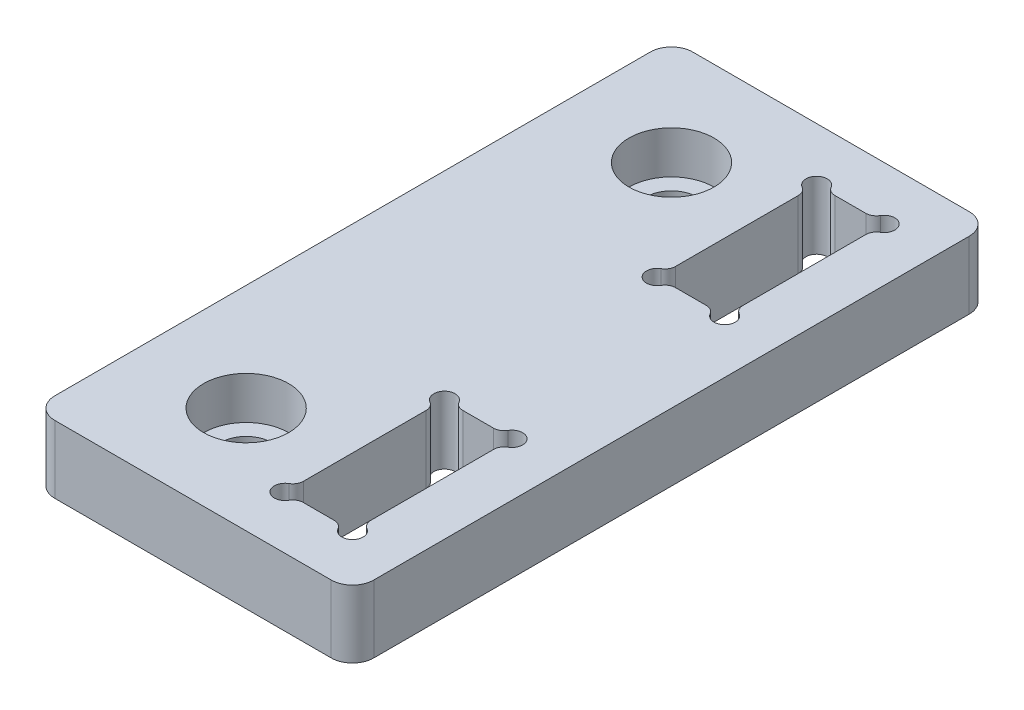
from build123d import *

# Parameters (mm, degrees)
SKETCH1_W                      = 30
SKETCH1_H                      = 60
BOSS_EXTRUDE1_DEPTH            = 6.35
CBORE_FOR_M4_SHCS1_D           = 4.8
CBORE_FOR_M4_SHCS1_DEPTH       = 6.35
CBORE_FOR_M4_SHCS1_CBORE_D     = 8
CBORE_FOR_M4_SHCS1_CBORE_DEPTH = 4
SKETCH4_W                      = 6.35
SKETCH4_H                      = 15
CUT_EXTRUDE1_DEPTH             = 7.35
SKETCH5_R                      = 1
CUT_EXTRUDE2_DEPTH             = 7.35
FILLET1_R                      = 1
FILLET2_R                      = 2


with BuildPart() as part:
    # Sketch1 → Boss-Extrude1 (new body)
    with BuildSketch(Plane(origin=(0, 0, 0), x_dir=(1, 0, 0), z_dir=(0, 1, 0))):
        Rectangle(SKETCH1_W, SKETCH1_H)
    extrude(amount=BOSS_EXTRUDE1_DEPTH)

    # CBORE for M4 SHCS1
    with Locations(Plane(origin=(0, 6.35, 0), x_dir=(1, 0, 0), z_dir=(0, 1, 0))):
        with Locations((-5, 20), (-5, -20)):
            CounterBoreHole(CBORE_FOR_M4_SHCS1_D / 2, CBORE_FOR_M4_SHCS1_CBORE_D / 2, CBORE_FOR_M4_SHCS1_CBORE_DEPTH, depth=CBORE_FOR_M4_SHCS1_DEPTH)

    # Sketch4 → Cut-Extrude1 (cut, through all)
    with BuildSketch(Plane(origin=(0, 6.35, 0), x_dir=(1, 0, 0), z_dir=(0, 1, 0))):
        with Locations((6.825, 17.5)):
            Rectangle(SKETCH4_W, SKETCH4_H)
    cut_extrude1 = extrude(amount=-CUT_EXTRUDE1_DEPTH, mode=Mode.SUBTRACT)

    # Sketch5 → Cut-Extrude2 (cut, through all)
    with BuildSketch(Plane(origin=(0, 6.35, 0), x_dir=(1, 0, 0), z_dir=(0, 1, 0))):
        with Locations((3.65, 25)):
            Circle(SKETCH5_R)
        with Locations((10, 25)):
            Circle(SKETCH5_R)
        with Locations((10, 10)):
            Circle(SKETCH5_R)
        with Locations((3.65, 10)):
            Circle(SKETCH5_R)
    cut_extrude2 = extrude(amount=-CUT_EXTRUDE2_DEPTH, mode=Mode.SUBTRACT)

    # Mirror1: Cut-Extrude1, Cut-Extrude2 across plane
    add(cut_extrude1.mirror(Plane.XY), mode=Mode.SUBTRACT)
    add(cut_extrude2.mirror(Plane.XY), mode=Mode.SUBTRACT)

    # Fillet1
    fillet1_edges = [part.edges().sort_by_distance(p)[0] for p in [
        (9, 3.175, 25),
        (10, 3.175, 11),
        (4.65, 3.175, 10),
        (3.65, 3.175, 11),
        (9, 3.175, 10),
        (10, 3.175, 24),
        (3.65, 3.175, 24),
        (9, 3.175, -10),
        (4.65, 3.175, -10),
        (10, 3.175, -24),
        (4.65, 3.175, -25),
        (3.65, 3.175, -11),
        (10, 3.175, -11),
        (9, 3.175, -25),
        (3.65, 3.175, -24),
        (4.65, 3.175, 25),
    ]]
    fillet(fillet1_edges, radius=FILLET1_R)

    # Fillet2
    fillet2_edges = [part.edges().sort_by_distance(p)[0] for p in [
        (-15, 3.175, -30),
        (15, 3.175, -30),
        (15, 3.175, 30),
        (-15, 3.175, 30),
    ]]
    fillet(fillet2_edges, radius=FILLET2_R)


solid = part.part
